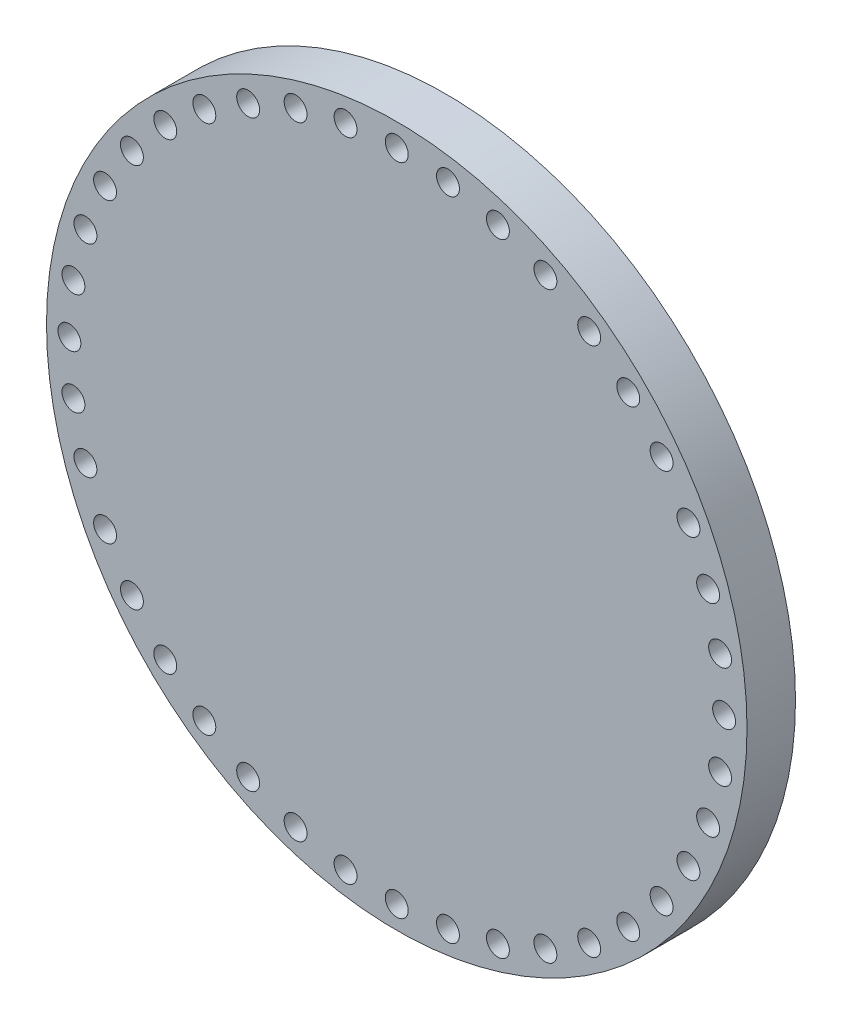
from build123d import *

# Parameters (mm, degrees)
SKETCH1_R           = 32.5
SKETCH1_R_2         = 1.0625
BOSS_EXTRUDE1_DEPTH = 4.5
SCALE1_SCALE        = 25.4


with BuildPart() as part:
    # Sketch1 → Boss-Extrude1 (new body)
    with BuildSketch(Plane.XY):
        Circle(SKETCH1_R)
        with Locations((0, 30.375)):
            Circle(SKETCH1_R_2, mode=Mode.SUBTRACT)
        with Locations((4.751696876, 30.001033346)):
            Circle(SKETCH1_R_2, mode=Mode.SUBTRACT)
        with Locations((9.386391204, 28.888341682)):
            Circle(SKETCH1_R_2, mode=Mode.SUBTRACT)
        with Locations((13.78996143, 27.064323172)):
            Circle(SKETCH1_R_2, mode=Mode.SUBTRACT)
        with Locations((17.853977038, 24.573891204)):
            Circle(SKETCH1_R_2, mode=Mode.SUBTRACT)
        with Locations((21.478368479, 21.478368479)):
            Circle(SKETCH1_R_2, mode=Mode.SUBTRACT)
        with Locations((24.573891204, 17.853977038)):
            Circle(SKETCH1_R_2, mode=Mode.SUBTRACT)
        with Locations((27.064323172, 13.78996143)):
            Circle(SKETCH1_R_2, mode=Mode.SUBTRACT)
        with Locations((28.888341682, 9.386391204)):
            Circle(SKETCH1_R_2, mode=Mode.SUBTRACT)
        with Locations((30.001033346, 4.751696876)):
            Circle(SKETCH1_R_2, mode=Mode.SUBTRACT)
        with Locations((30.375, 0)):
            Circle(SKETCH1_R_2, mode=Mode.SUBTRACT)
        with Locations((30.001033346, -4.751696876)):
            Circle(SKETCH1_R_2, mode=Mode.SUBTRACT)
        with Locations((28.888341682, -9.386391204)):
            Circle(SKETCH1_R_2, mode=Mode.SUBTRACT)
        with Locations((27.064323172, -13.78996143)):
            Circle(SKETCH1_R_2, mode=Mode.SUBTRACT)
        with Locations((24.573891204, -17.853977038)):
            Circle(SKETCH1_R_2, mode=Mode.SUBTRACT)
        with Locations((21.478368479, -21.478368479)):
            Circle(SKETCH1_R_2, mode=Mode.SUBTRACT)
        with Locations((17.853977038, -24.573891204)):
            Circle(SKETCH1_R_2, mode=Mode.SUBTRACT)
        with Locations((13.78996143, -27.064323172)):
            Circle(SKETCH1_R_2, mode=Mode.SUBTRACT)
        with Locations((9.386391204, -28.888341682)):
            Circle(SKETCH1_R_2, mode=Mode.SUBTRACT)
        with Locations((4.751696876, -30.001033346)):
            Circle(SKETCH1_R_2, mode=Mode.SUBTRACT)
        with Locations((0, -30.375)):
            Circle(SKETCH1_R_2, mode=Mode.SUBTRACT)
        with Locations((-4.751696876, -30.001033346)):
            Circle(SKETCH1_R_2, mode=Mode.SUBTRACT)
        with Locations((-9.386391204, -28.888341682)):
            Circle(SKETCH1_R_2, mode=Mode.SUBTRACT)
        with Locations((-13.78996143, -27.064323172)):
            Circle(SKETCH1_R_2, mode=Mode.SUBTRACT)
        with Locations((-17.853977038, -24.573891204)):
            Circle(SKETCH1_R_2, mode=Mode.SUBTRACT)
        with Locations((-21.478368479, -21.478368479)):
            Circle(SKETCH1_R_2, mode=Mode.SUBTRACT)
        with Locations((-24.573891204, -17.853977038)):
            Circle(SKETCH1_R_2, mode=Mode.SUBTRACT)
        with Locations((-27.064323172, -13.78996143)):
            Circle(SKETCH1_R_2, mode=Mode.SUBTRACT)
        with Locations((-28.888341682, -9.386391204)):
            Circle(SKETCH1_R_2, mode=Mode.SUBTRACT)
        with Locations((-30.001033346, -4.751696876)):
            Circle(SKETCH1_R_2, mode=Mode.SUBTRACT)
        with Locations((-30.375, 0)):
            Circle(SKETCH1_R_2, mode=Mode.SUBTRACT)
        with Locations((-30.001033346, 4.751696876)):
            Circle(SKETCH1_R_2, mode=Mode.SUBTRACT)
        with Locations((-28.888341682, 9.386391204)):
            Circle(SKETCH1_R_2, mode=Mode.SUBTRACT)
        with Locations((-27.064323172, 13.78996143)):
            Circle(SKETCH1_R_2, mode=Mode.SUBTRACT)
        with Locations((-24.573891204, 17.853977038)):
            Circle(SKETCH1_R_2, mode=Mode.SUBTRACT)
        with Locations((-21.478368479, 21.478368479)):
            Circle(SKETCH1_R_2, mode=Mode.SUBTRACT)
        with Locations((-17.853977038, 24.573891204)):
            Circle(SKETCH1_R_2, mode=Mode.SUBTRACT)
        with Locations((-13.78996143, 27.064323172)):
            Circle(SKETCH1_R_2, mode=Mode.SUBTRACT)
        with Locations((-9.386391204, 28.888341682)):
            Circle(SKETCH1_R_2, mode=Mode.SUBTRACT)
        with Locations((-4.751696876, 30.001033346)):
            Circle(SKETCH1_R_2, mode=Mode.SUBTRACT)
    extrude(amount=BOSS_EXTRUDE1_DEPTH)


with BuildPart() as part_1:
    # Scale1: scaled about (0, 0, 2.25)
    add(part.part.scale(SCALE1_SCALE).moved(Location((0, 0, -54.9))))


solid = part_1.part
